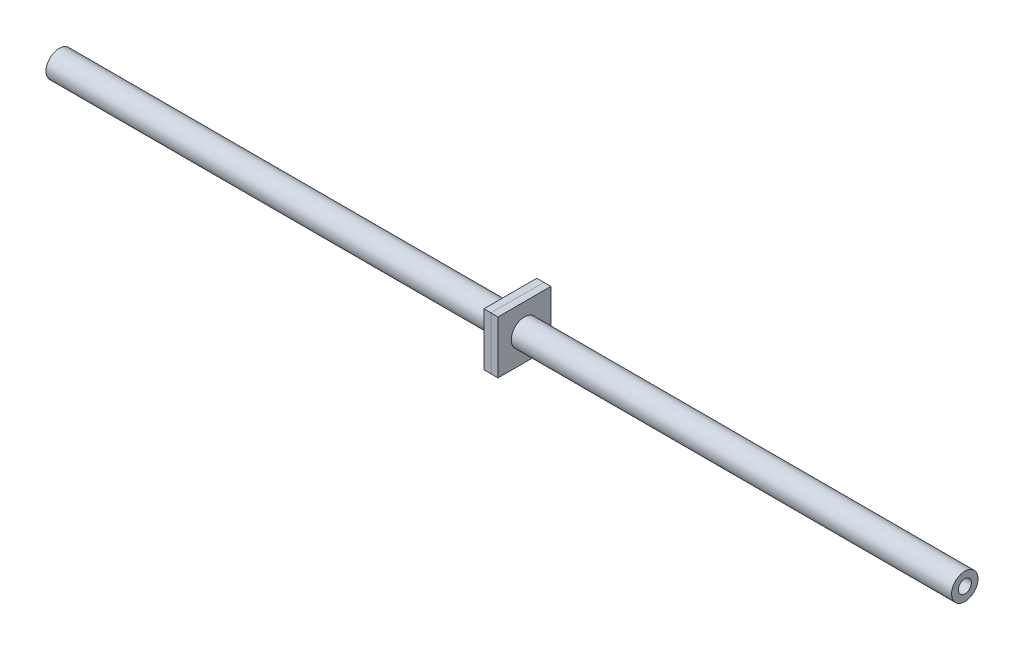
from build123d import *

# Parameters (mm, degrees)
SKETCH1_R                 = 4.7625
SKETCH1_R_2               = 2.3495
STEERING_ROD_MEMBER_DEPTH = 326.310830854
STEERING_START            = 165.1
SKETCH2_W                 = 19.05
SKETCH2_H                 = 19.05
SKETCH2_R                 = 4.7625
STEERING_ROD_NUT_1_DEPTH  = 2.54
SKETCH3_W                 = 19.05
SKETCH3_H                 = 19.05
SKETCH3_R                 = 4.7625
STEERING_ROD_NUT_2_DEPTH  = 2.54


with BuildPart() as part:
    # Sketch1 → Steering Rod Member (new body)
    with BuildSketch(Plane.YZ):
        Circle(SKETCH1_R)
        Circle(SKETCH1_R_2, mode=Mode.SUBTRACT)
    extrude(amount=STEERING_ROD_MEMBER_DEPTH)


with BuildPart() as body_2:
    # Sketch2 → Steering Rod Nut 1 (new body)
    with BuildSketch(Plane(origin=(0, 0, 0), x_dir=(0, 0, -1), z_dir=(1, 0, 0)).offset(STEERING_START)):
        Rectangle(SKETCH2_W, SKETCH2_H)
        Circle(SKETCH2_R, mode=Mode.SUBTRACT)
    extrude(amount=STEERING_ROD_NUT_1_DEPTH)


with BuildPart() as body_3:
    # Sketch3 → Steering Rod Nut 2 (new body)
    with BuildSketch(Plane(origin=(0, 0, 0), x_dir=(0, 0, -1), z_dir=(1, 0, 0)).offset(STEERING_START)):
        Rectangle(SKETCH3_W, SKETCH3_H)
        with Locations(Location((0, 0, 0), (0, 0, 180))):
            Circle(SKETCH3_R, mode=Mode.SUBTRACT)
    extrude(amount=-STEERING_ROD_NUT_2_DEPTH)


solid = Compound([part.part, body_2.part, body_3.part])
